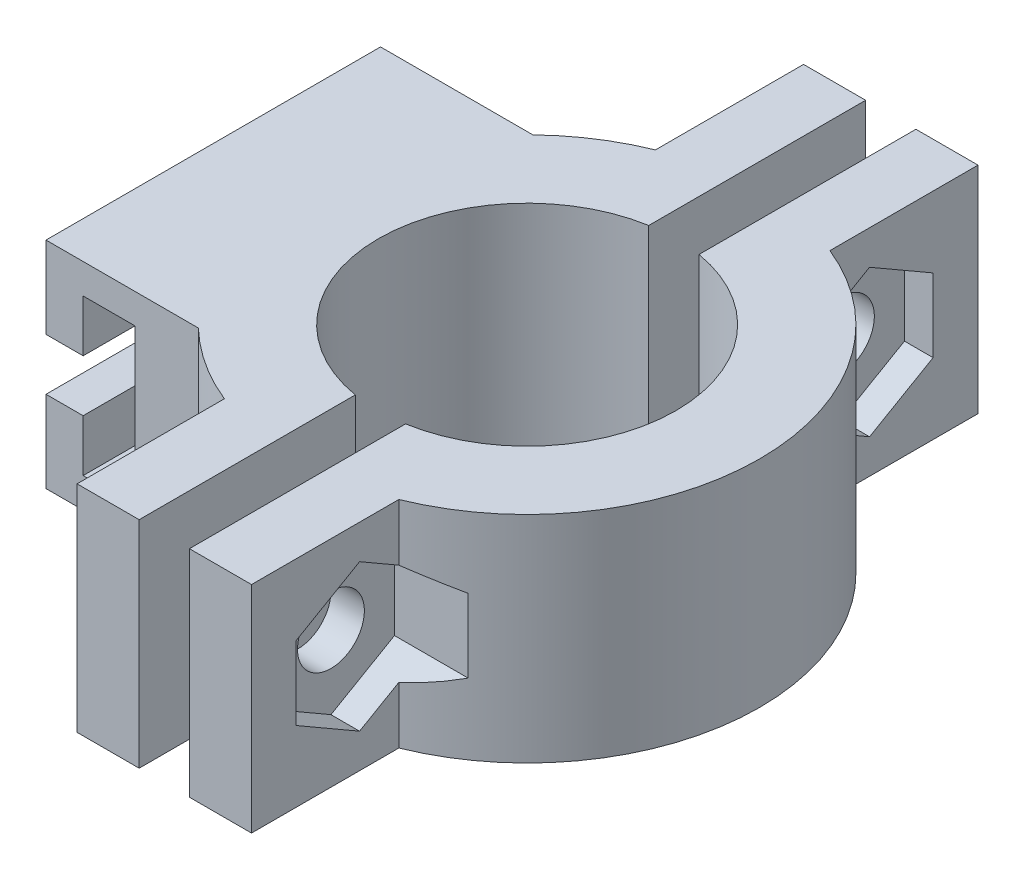
from build123d import *

# Parameters (mm, degrees)
BOSS_EXTRUDE1_DEPTH      = 16.343724405
BOSS_EXTRUDE1_2_DEPTH    = 16.343724405
CUT_EXTRUDE1_START       = 2.54
CUT_EXTRUDE1_DEPTH       = 11.43
BOSS_EXTRUDE2_DEPTH      = 12.7
BOSS_EXTRUDE2_DEPTH_BACK = 12.7
SKETCH3_3_W              = 2.8194
SKETCH3_3_H              = 3.937
SKETCH3_3_W_2            = 0.578220869
SKETCH3_3_H_2            = 11.811
CUT_EXTRUDE5_DEPTH       = 28.549251506
CUT_EXTRUDE5_DEPTH_BACK  = 28.609404293
SKETCH2_7_R              = 2.54
CUT_EXTRUDE6_DEPTH       = 16.744973729
CUT_EXTRUDE6_DEPTH_BACK  = 26.739205402
CUT_EXTRUDE7_START       = -8.53076
SKETCH2_8_R              = 6.35
CUT_EXTRUDE7_DEPTH       = 24.638


with BuildPart() as part:
    # Sketch1 → Boss-Extrude1 (new body)
    with BuildSketch(Plane(origin=(0, 0, 0), x_dir=(1, 0, 0), z_dir=(0, 1, 0))):
        with BuildLine():
            Line((1.908026271, -27.549251506), (6.622734164, -27.549251506))
            Line((6.622734164, -27.549251506), (6.622734164, -16.363612107))
            ThreePointArc((6.622734164, -16.363612107), (17.653, 0), (6.622734164, 16.363612107))
            Line((6.622734164, 16.363612107), (6.622734164, 27.609404293))
            Line((6.622734164, 27.609404293), (1.908026271, 27.609404293))
            Line((1.908026271, 27.609404293), (1.908026271, 11.140791926))
            ThreePointArc((1.908026271, 11.140791926), (11.303, 0), (1.908026271, -11.140791926))
            Line((1.908026271, -11.140791926), (1.908026271, -27.549251506))
        make_face()
    extrude(amount=BOSS_EXTRUDE1_DEPTH)

    # Sketch2 → Cut-Extrude1 (cut)
    with BuildSketch(Plane(origin=(1.908026271, 0, 1.908026271), x_dir=(0, 0, -1), z_dir=(1, 0, 0)).offset(CUT_EXTRUDE1_START)):
        Polygon((21.283124381, 2.599277405), (26.109124381, 5.385569804), (26.109124381, 10.958154602), (21.283124381, 13.744447001), (16.457124381, 10.958154602), (16.457124381, 5.385569804), align=None)
        Polygon((-17.436995445, 2.599277405), (-12.610995445, 5.385569804), (-12.610995445, 10.958154602), (-17.436995445, 13.744447001), (-22.262995445, 10.958154602), (-22.262995445, 5.385569804), align=None)
    extrude(amount=CUT_EXTRUDE1_DEPTH, mode=Mode.SUBTRACT)


with BuildPart() as body_2:
    # Sketch1 → Boss-Extrude1 2 (new body)
    with BuildSketch(Plane(origin=(0, 0, 0), x_dir=(1, 0, 0), z_dir=(0, 1, 0))):
        with BuildLine():
            Line((-6.622734164, -27.549251506), (-1.908026271, -27.549251506))
            Line((-1.908026271, -27.549251506), (-1.908026271, -11.140791926))
            ThreePointArc((-1.908026271, -11.140791926), (-11.303, 0), (-1.908026271, 11.140791926))
            Line((-1.908026271, 11.140791926), (-1.908026271, 27.609404293))
            Line((-1.908026271, 27.609404293), (-6.622734164, 27.609404293))
            Line((-6.622734164, 27.609404293), (-6.622734164, 16.363612107))
            ThreePointArc((-6.622734164, 16.363612107), (-17.653, 0), (-6.622734164, -16.363612107))
            Line((-6.622734164, -16.363612107), (-6.622734164, -27.549251506))
        make_face()
    extrude(amount=BOSS_EXTRUDE1_2_DEPTH)

    # Sketch3 → Boss-Extrude2 (add, two sides)
    with BuildSketch(Plane.XY) as boss_extrude2_sk:
        Polygon((-23.831179131, 0), (-17.653, 0), (-17.653, 2.266362203), (-21.011779131, 2.266362203), (-21.011779131, 6.203362203), (-23.831179131, 6.203362203), align=None)
        Polygon((-11.957162625, 0), (-11.957162625, 16.343724405), (-17.653, 16.343724405), (-17.653, 14.077362203), (-17.074779131, 14.077362203), (-17.074779131, 2.266362203), (-17.653, 2.266362203), (-17.653, 0), align=None)
        Polygon((-17.653, 14.077362203), (-17.653, 16.343724405), (-23.831179131, 16.343724405), (-23.831179131, 10.140362203), (-21.011779131, 10.140362203), (-21.011779131, 14.077362203), align=None)
    extrude(amount=BOSS_EXTRUDE2_DEPTH)
    extrude(boss_extrude2_sk.sketch, amount=-BOSS_EXTRUDE2_DEPTH_BACK)

    # Sketch3_3 → Cut-Extrude5 (cut, two sides)
    with BuildSketch(Plane.XY) as cut_extrude5_sk:
        Polygon((-17.653, 2.266362203), (-17.653, 14.077362203), (-21.011779131, 14.077362203), (-21.011779131, 10.140362203), (-21.011779131, 6.203362203), (-21.011779131, 2.266362203), align=None)
        with Locations((-22.421479131, 8.171862203)):
            Rectangle(SKETCH3_3_W, SKETCH3_3_H)
        with Locations((-17.363889566, 8.171862203)):
            Rectangle(SKETCH3_3_W_2, SKETCH3_3_H_2)
    extrude(amount=CUT_EXTRUDE5_DEPTH, mode=Mode.SUBTRACT)
    extrude(cut_extrude5_sk.sketch, amount=-CUT_EXTRUDE5_DEPTH_BACK, mode=Mode.SUBTRACT)


with BuildPart() as cut_extrude6_tool:
    # Sketch2_7 → Cut-Extrude6 (new body, two sides)
    with BuildSketch(Plane(origin=(1.908026271, 0, 1.908026271), x_dir=(0, 0, -1), z_dir=(1, 0, 0))) as cut_extrude6_sk:
        with Locations((21.283124381, 8.171862203)):
            Circle(SKETCH2_7_R)
        with Locations((-17.436995445, 8.171862203)):
            Circle(SKETCH2_7_R)
    extrude(amount=CUT_EXTRUDE6_DEPTH)
    extrude(cut_extrude6_sk.sketch, amount=-CUT_EXTRUDE6_DEPTH_BACK)


with BuildPart() as part_1:
    add(part.part)

    # Cut-Extrude6: cut by cut_extrude6_tool
    add(cut_extrude6_tool.part, mode=Mode.SUBTRACT)


with BuildPart() as body_2_1:
    add(body_2.part)

    # Cut-Extrude6: cut by cut_extrude6_tool
    add(cut_extrude6_tool.part, mode=Mode.SUBTRACT)

    # Sketch2_8 → Cut-Extrude7 (cut)
    with BuildSketch(Plane(origin=(1.908026271, 0, 1.908026271), x_dir=(0, 0, -1), z_dir=(1, 0, 0)).offset(CUT_EXTRUDE7_START)):
        with Locations((21.283124381, 8.171862203)):
            Circle(SKETCH2_8_R)
        with Locations((-17.436995445, 8.171862203)):
            Circle(SKETCH2_8_R)
    extrude(amount=-CUT_EXTRUDE7_DEPTH, mode=Mode.SUBTRACT)


solid = Compound([part_1.part, body_2_1.part])
